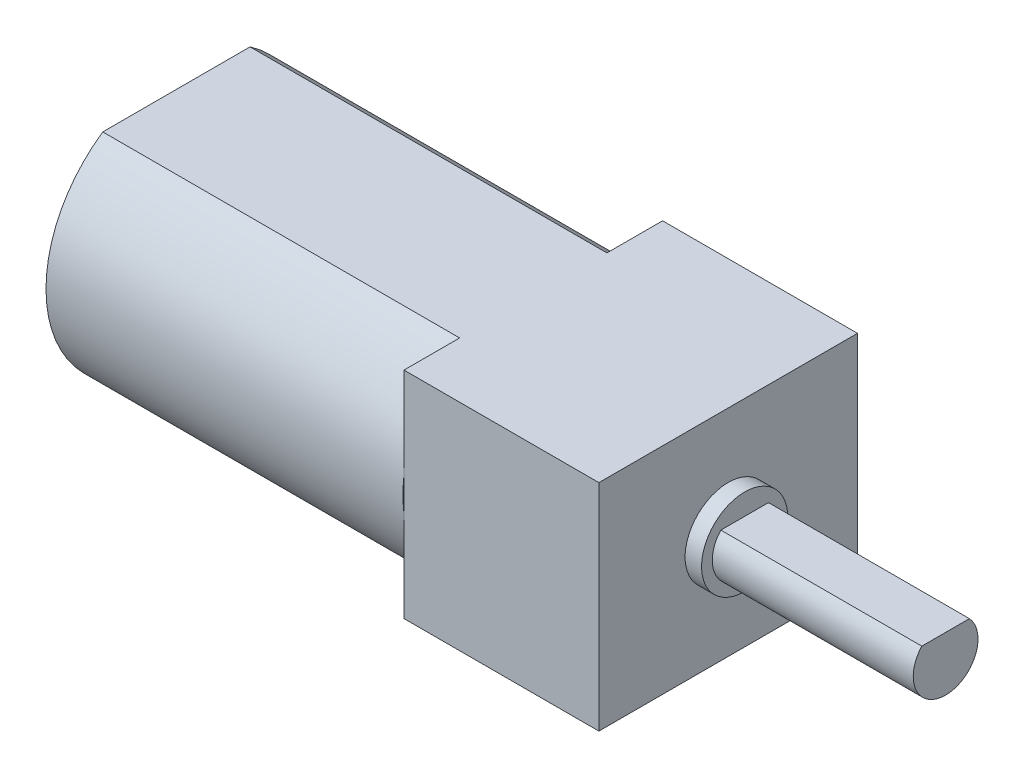
from build123d import *

# Parameters (mm, degrees)
SKETCH1_W           = 11.9634
SKETCH1_H           = 9.9568
BOSS_EXTRUDE1_DEPTH = 9.017
BOSS_EXTRUDE2_DEPTH = 10.0584
SKETCH3_R           = 1.9939
BOSS_EXTRUDE3_DEPTH = 0.762
BOSS_EXTRUDE4_DEPTH = 16.51


with BuildPart() as part:
    # Sketch1 → Boss-Extrude1 (new body)
    with BuildSketch(Plane(origin=(0, 0, 0), x_dir=(0, 0, -1), z_dir=(1, 0, 0))):
        Rectangle(SKETCH1_W, SKETCH1_H)
    extrude(amount=-BOSS_EXTRUDE1_DEPTH)

    # Sketch2 → Boss-Extrude2 (add)
    with BuildSketch(Plane(origin=(0, 0, 0), x_dir=(0, 0, -1), z_dir=(1, 0, 0))):
        with BuildLine():
            Line((-1.101610621, 1.016), (1.101610621, 1.016))
            ThreePointArc((1.101610621, 1.016), (0, -1.4986), (-1.101610621, 1.016))
        make_face()
    extrude(amount=BOSS_EXTRUDE2_DEPTH)

    # Sketch3 → Boss-Extrude3 (add)
    with BuildSketch(Plane(origin=(0, 0, 0), x_dir=(0, 0, -1), z_dir=(1, 0, 0))):
        Circle(SKETCH3_R)
    extrude(amount=BOSS_EXTRUDE3_DEPTH)

    # Sketch4 → Boss-Extrude4 (add)
    with BuildSketch(Plane.ZY.offset(9.017)):
        with BuildLine():
            Line((-3.406844536, 4.9784), (3.406844536, 4.9784))
            ThreePointArc((3.406844536, 4.9784), (6.0325, 0), (3.406844536, -4.9784))
            Line((3.406844536, -4.9784), (-3.406844536, -4.9784))
            ThreePointArc((-3.406844536, -4.9784), (-6.0325, 0), (-3.406844536, 4.9784))
        make_face()
    extrude(amount=BOSS_EXTRUDE4_DEPTH)


solid = part.part
